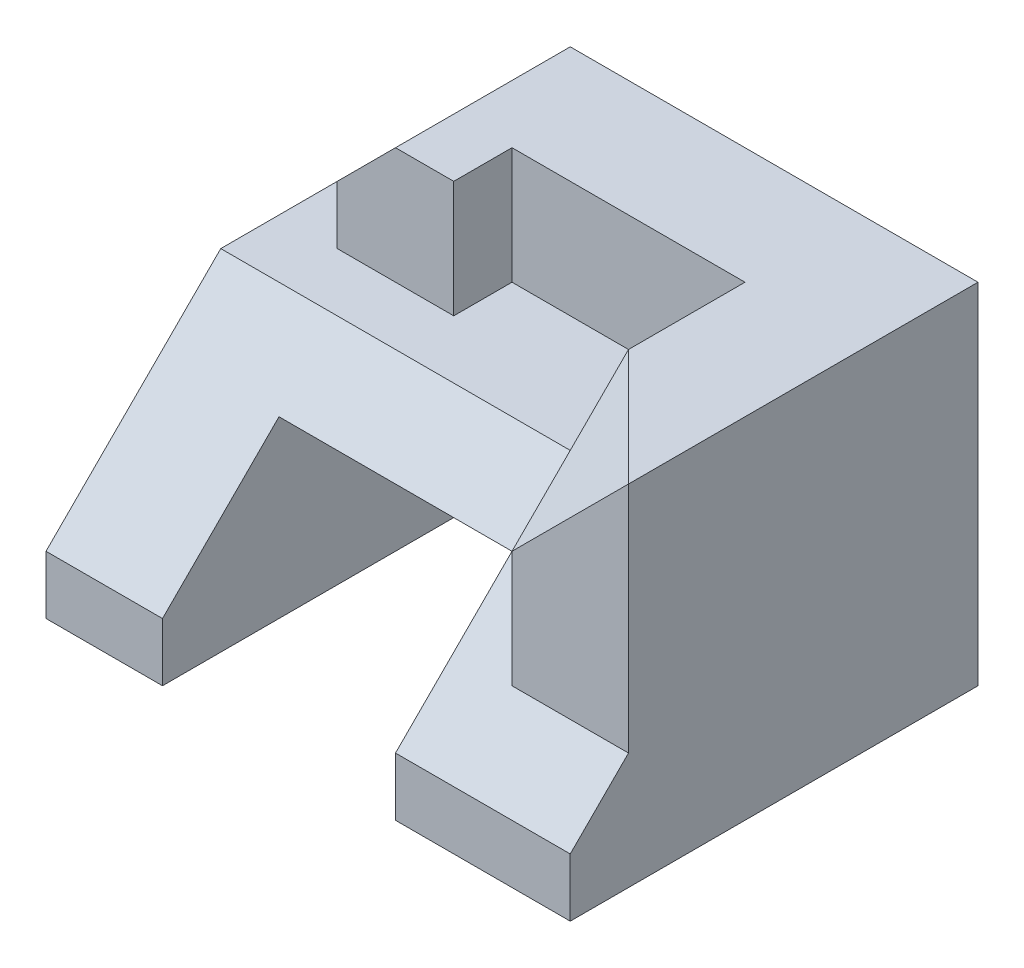
from build123d import *

# Parameters (mm, degrees)
SKETCH1_W           = 50
SKETCH1_H           = 20
BOSS_EXTRUDE1_DEPTH = 30
SKETCH2_W           = 20
SKETCH2_H           = 15
CUT_EXTRUDE1_DEPTH  = 31
SKETCH3_W           = 5
SKETCH3_H           = 20
CUT_EXTRUDE2_DEPTH  = 20
CUT_EXTRUDE3_DEPTH  = 11
CUT_EXTRUDE4_DEPTH  = 46
SKETCH7_W           = 40
SKETCH7_H           = 30
BOSS_EXTRUDE2_DEPTH = 5
SKETCH8_W           = 20
SKETCH8_H           = 15
CUT_EXTRUDE5_DEPTH  = 6
SKETCH9_W           = 40
SKETCH9_H           = 10
BOSS_EXTRUDE3_DEPTH = 10
SKETCH10_W          = 20
SKETCH10_H          = 10
CUT_EXTRUDE6_DEPTH  = 5
CUT_EXTRUDE7_DEPTH  = 16
SKETCH12_W          = 10
SKETCH12_H          = 10
BOSS_EXTRUDE4_DEPTH = 5
SKETCH13_W          = 10
SKETCH13_H          = 10
BOSS_EXTRUDE5_DEPTH = 10
SKETCH14_W          = 10
SKETCH14_H          = 10
BOSS_EXTRUDE6_DEPTH = 10
CUT_EXTRUDE8_DEPTH  = 10


with BuildPart() as part:
    # Sketch1 → Boss-Extrude1 (new body)
    with BuildSketch(Plane.XY):
        Rectangle(SKETCH1_W, SKETCH1_H)
    extrude(amount=BOSS_EXTRUDE1_DEPTH)

    # Sketch2 → Cut-Extrude1 (cut, through all)
    with BuildSketch(Plane.XY.offset(30)):
        with Locations((0, -2.5)):
            Rectangle(SKETCH2_W, SKETCH2_H)
    extrude(amount=-CUT_EXTRUDE1_DEPTH, mode=Mode.SUBTRACT)

    # Sketch3 → Cut-Extrude2 (cut)
    with BuildSketch(Plane.XY.offset(30)):
        with Locations((-22.5, 0)):
            Rectangle(SKETCH3_W, SKETCH3_H)
    extrude(amount=-CUT_EXTRUDE2_DEPTH, mode=Mode.SUBTRACT)

    # Sketch4 → Cut-Extrude3 (cut, through all)
    with BuildSketch(Plane.XY.offset(10)):
        Polygon((-20, 10), (-25, 0), (-25, 10), align=None)
    extrude(amount=-CUT_EXTRUDE3_DEPTH, mode=Mode.SUBTRACT)

    # Sketch5 → Cut-Extrude4 (cut, through all)
    with BuildSketch(Plane.ZY.offset(20)):
        Polygon((15, 10), (30, -5), (30, 10), align=None)
    extrude(amount=-CUT_EXTRUDE4_DEPTH, mode=Mode.SUBTRACT)

    # Sketch7 → Boss-Extrude2 (add)
    with BuildSketch(Plane(origin=(0, 0, 0), x_dir=(-1, 0, 0), z_dir=(0, 0, -1))):
        with Locations((-5, 5)):
            Rectangle(SKETCH7_W, SKETCH7_H)
    extrude(amount=BOSS_EXTRUDE2_DEPTH)

    # Sketch8 → Cut-Extrude5 (cut, through all)
    with BuildSketch(Plane.XY):
        with Locations((0, -2.5)):
            Rectangle(SKETCH8_W, SKETCH8_H)
    extrude(amount=-CUT_EXTRUDE5_DEPTH, mode=Mode.SUBTRACT)

    # Sketch9 → Boss-Extrude3 (add)
    with BuildSketch(Plane(origin=(0, 10, 0), x_dir=(1, 0, 0), z_dir=(0, 1, 0))):
        with Locations((5, -5)):
            Rectangle(SKETCH9_W, SKETCH9_H)
    extrude(amount=BOSS_EXTRUDE3_DEPTH)

    # Sketch10 → Cut-Extrude6 (cut)
    with BuildSketch(Plane.XY.offset(10)):
        with Locations((5, 15)):
            Rectangle(SKETCH10_W, SKETCH10_H)
    extrude(amount=-CUT_EXTRUDE6_DEPTH, mode=Mode.SUBTRACT)

    # Sketch11 → Cut-Extrude7 (cut, through all)
    with BuildSketch(Plane.XY.offset(10)):
        Polygon((-15, 20), (-10, 20), (-15, 15), align=None)
    extrude(amount=-CUT_EXTRUDE7_DEPTH, mode=Mode.SUBTRACT)

    # Sketch12 → Boss-Extrude4 (add)
    with BuildSketch(Plane.XY.offset(10)):
        with Locations((20, 15)):
            Rectangle(SKETCH12_W, SKETCH12_H)
    extrude(amount=BOSS_EXTRUDE4_DEPTH)

    # Sketch13 → Boss-Extrude5 (add)
    with BuildSketch(Plane.XY.offset(15)):
        with Locations((20, 15)):
            Rectangle(SKETCH13_W, SKETCH13_H)
    extrude(amount=BOSS_EXTRUDE5_DEPTH)

    # Sketch14 → Boss-Extrude6 (add)
    with BuildSketch(Plane.XZ.offset(-10)):
        with Locations((20, 20)):
            Rectangle(SKETCH14_W, SKETCH14_H)
    extrude(amount=BOSS_EXTRUDE6_DEPTH)

    # Sketch17 → Cut-Extrude8 (cut)
    with BuildSketch(Plane(origin=(-6.666666667, 6.666666667, 6.666666667), x_dir=(0.816496581, 0.40824829, 0.40824829), z_dir=(-0.577350269, 0.577350269, 0.577350269))):
        Polygon((26.53613888, 3.535533906), (38.783587594, -3.535533906), (26.53613888, -10.606601718), align=None)
    extrude(amount=CUT_EXTRUDE8_DEPTH, mode=Mode.SUBTRACT)


solid = part.part
